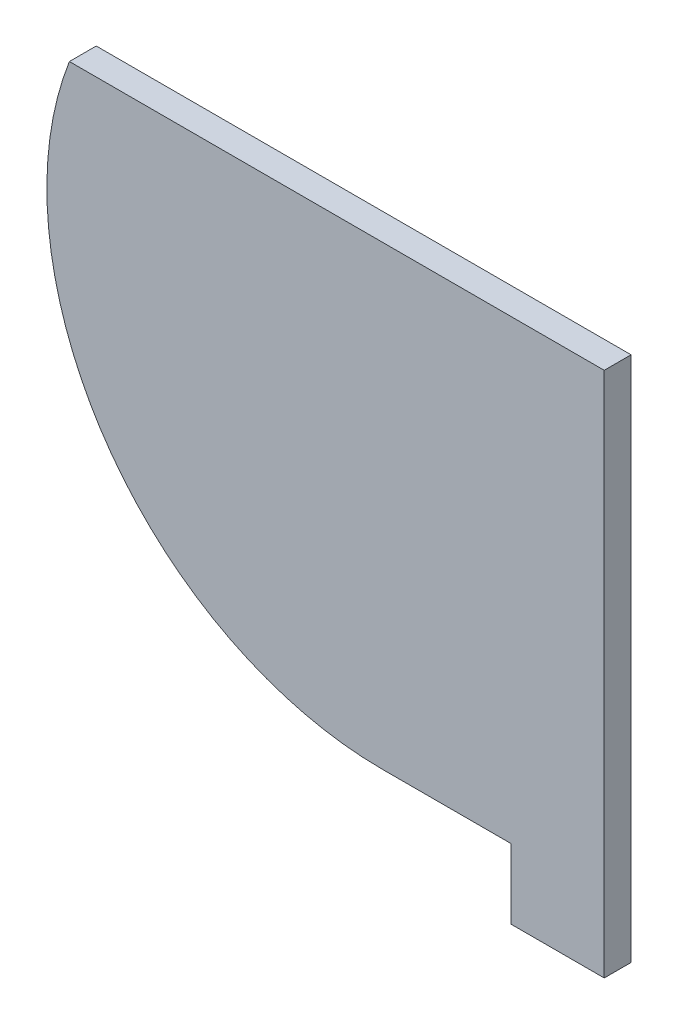
from build123d import *

# Parameters (mm, degrees)
BOSS_EXTRUDE1_DEPTH = 5
SKETCH2_W           = 17.35
SKETCH2_H           = 13
BOSS_EXTRUDE2_DEPTH = 5


with BuildPart() as part:
    # Sketch1 → Boss-Extrude1 (new body)
    with BuildSketch(Plane.XY):
        with BuildLine():
            Line((0, 0), (0, -85))
            Line((0, -85), (-41.280574715, -85))
            ThreePointArc((-41.280574715, -85), (-92.819395035, -57.855339059), (-99.590093663, 0))
            Line((-99.590093663, 0), (0, 0))
        make_face()
    extrude(amount=BOSS_EXTRUDE1_DEPTH)

    # Sketch2 → Boss-Extrude2 (add)
    with BuildSketch(Plane.XY.offset(5)):
        with Locations((-8.675, -91.5)):
            Rectangle(SKETCH2_W, SKETCH2_H)
    extrude(amount=-BOSS_EXTRUDE2_DEPTH)


solid = part.part
